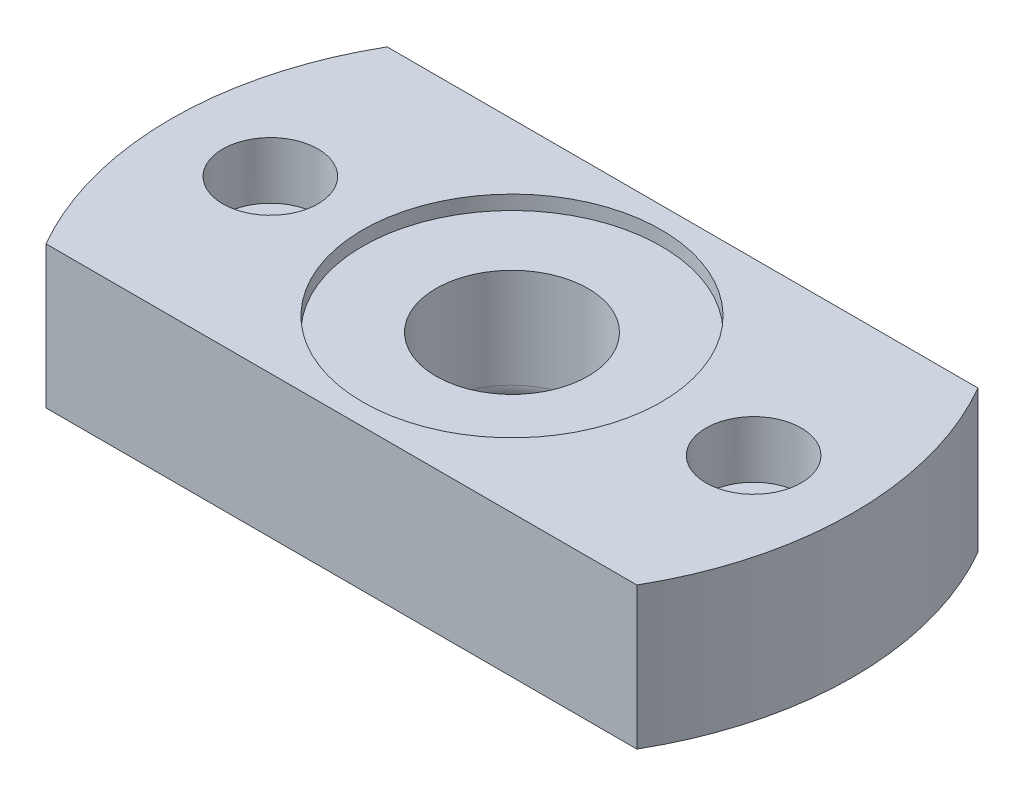
from build123d import *

# Parameters (mm, degrees)
SKETCH1_R           = 12
SKETCH1_R_2         = 2.675
BOSS_EXTRUDE1_DEPTH = 5
SKETCH3_R           = 1.675
CUT_EXTRUDE1_DEPTH  = 6
CUT_EXTRUDE2_DEPTH  = 2.5
CUT_EXTRUDE4_DEPTH  = 10
FILLET1_R           = 1
SKETCH7_R           = 5.25
CUT_EXTRUDE5_DEPTH  = 0.5
SKETCH8_R           = 1.675
BOSS_EXTRUDE2_DEPTH = 0.5


with BuildPart() as part:
    # Sketch1 → Boss-Extrude1 (new body)
    with BuildSketch(Plane(origin=(0, 0, 0), x_dir=(1, 0, 0), z_dir=(0, 1, 0))):
        Circle(SKETCH1_R)
        Circle(SKETCH1_R_2, mode=Mode.SUBTRACT)
    extrude(amount=BOSS_EXTRUDE1_DEPTH)

    # Sketch3 → Cut-Extrude1 (cut)
    with BuildSketch(Plane(origin=(0, 5, 0), x_dir=(1, 0, 0), z_dir=(0, 1, 0))):
        with Locations((-8.5, 0)):
            Circle(SKETCH3_R)
        with Locations((8.5, 0)):
            Circle(SKETCH3_R)
    extrude(amount=-CUT_EXTRUDE1_DEPTH, mode=Mode.SUBTRACT)

    # Sketch4 → Cut-Extrude2 (cut)
    with BuildSketch(Plane.XZ):
        Polygon((-11.425, -1.688749537), (-8.5, -3.377499075), (-5.575, -1.688749537), (-5.575, 1.688749537), (-8.5, 3.377499075), (-11.425, 1.688749537), align=None)
        Polygon((11.425, 1.688749537), (11.425, -1.688749537), (8.5, -3.377499075), (5.575, -1.688749537), (5.575, 1.688749537), (8.5, 3.377499075), align=None)
    extrude(amount=-CUT_EXTRUDE2_DEPTH, mode=Mode.SUBTRACT)

    # Sketch6 → Cut-Extrude4 (cut)
    with BuildSketch(Plane.XZ):
        with BuildLine():
            Line((-10.392304845, 6), (10.392304845, 6))
            ThreePointArc((10.392304845, 6), (0, 12), (-10.392304845, 6))
        make_face()
        with BuildLine():
            Line((-10.392304845, -6), (10.392304845, -6))
            ThreePointArc((10.392304845, -6), (0, -12), (-10.392304845, -6))
        make_face()
    extrude(amount=-CUT_EXTRUDE4_DEPTH, mode=Mode.SUBTRACT)

    # Fillet1
    fillet1_edges = [part.edges().sort_by_distance(p)[0] for p in [
        (-2.675, 0, 0),
    ]]
    fillet(fillet1_edges, radius=FILLET1_R)

    # Sketch7 → Cut-Extrude5 (cut)
    with BuildSketch(Plane(origin=(0, 5, 0), x_dir=(1, 0, 0), z_dir=(0, 1, 0))):
        Circle(SKETCH7_R)
    extrude(amount=-CUT_EXTRUDE5_DEPTH, mode=Mode.SUBTRACT)

    # Sketch8 → Boss-Extrude2 (add)
    with BuildSketch(Plane.XZ.offset(-2.5)):
        with Locations((8.5, 0)):
            Circle(SKETCH8_R)
        with Locations((-8.5, 0)):
            Circle(SKETCH8_R)
    extrude(amount=-BOSS_EXTRUDE2_DEPTH)


solid = part.part
